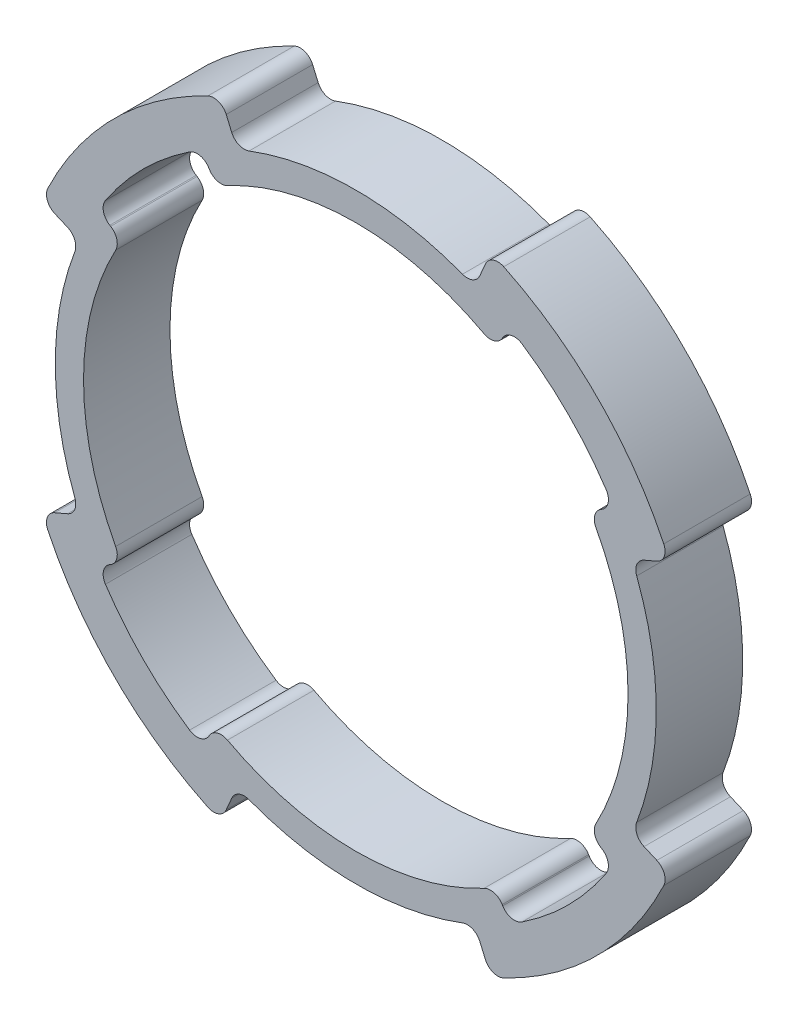
from build123d import *

# Parameters (mm, degrees)
SKETCH1_R                = 50.2
SKETCH1_R_2              = 40
BOSS_EXTRUDE1_DEPTH      = 12.7
CUT_EXTRUDE1_DEPTH       = 13.7
FILLET1_R                = 2
CIRPATTERN1_COUNT        = 4
FILLET1_OF_CIRPATTERN1_R = 2


with BuildPart() as part:
    # Sketch1 → Boss-Extrude1 (new body)
    with BuildSketch(Plane.XY):
        Circle(SKETCH1_R)
        Circle(SKETCH1_R_2, mode=Mode.SUBTRACT)
    extrude(amount=BOSS_EXTRUDE1_DEPTH)

    # Sketch2 → Cut-Extrude1 (cut, through all)
    with BuildSketch(Plane(origin=(0, 0, 0), x_dir=(-1, 0, 0), z_dir=(0, 0, -1))):
        with BuildLine():
            Line((-37.903382312, 22.639702058), (0, 0))
            Line((0, 0), (-22.639702058, 37.903382312))
            ThreePointArc((-22.639702058, 37.903382312), (-31.218764389, 31.218764389), (-37.903382312, 22.639702058))
        make_face()
        with BuildLine():
            Line((-46.112060645, 19.842325042), (-40.554730627, 17.450969136))
            ThreePointArc((-40.554730627, 17.450969136), (-44.15, 0), (-40.554730627, -17.450969136))
            Line((-40.554730627, -17.450969136), (-46.112060645, -19.842325042))
            ThreePointArc((-46.112060645, -19.842325042), (-50.2, 0), (-46.112060645, 19.842325042))
        make_face()
    cut_extrude1 = extrude(amount=-CUT_EXTRUDE1_DEPTH, mode=Mode.SUBTRACT)

    # Fillet1
    fillet1_edges = [part.edges().sort_by_distance(p)[0] for p in [
        (34.340550226, 20.511621344, 6.35),
        (20.511621344, 34.340550226, 6.35),
        (22.639702058, 37.903382312, 6.35),
        (37.903382312, 22.639702058, 6.35),
        (40.554730627, 17.450969136, 6.35),
        (40.554730627, -17.450969136, 6.35),
        (46.112060645, -19.842325042, 6.35),
        (46.112060645, 19.842325042, 6.35),
    ]]
    fillet(fillet1_edges, radius=FILLET1_R)

    # CirPattern1: Cut-Extrude1 ×4 about axis
    cirpattern1_axis = Axis((0, 0, 0), (0, 0, 1))
    for i in range(1, CIRPATTERN1_COUNT):
        add(cut_extrude1.rotate(cirpattern1_axis, i * 360 / CIRPATTERN1_COUNT), mode=Mode.SUBTRACT)

    # Fillet1 of CirPattern1
    fillet1_of_cirpattern1_edges = [part.edges().sort_by_distance(p)[0] for p in [
        (-20.511621344, 34.340550226, 6.35),
        (-34.340550226, 20.511621344, 6.35),
        (-37.903382312, 22.639702058, 6.35),
        (-22.639702058, 37.903382312, 6.35),
        (-17.450969136, 40.554730627, 6.35),
        (17.450969136, 40.554730627, 6.35),
        (19.842325042, 46.112060645, 6.35),
        (-19.842325042, 46.112060645, 6.35),
        (-34.340550226, -20.511621344, 6.35),
        (-20.511621344, -34.340550226, 6.35),
        (-22.639702058, -37.903382312, 6.35),
        (-37.903382312, -22.639702058, 6.35),
        (-40.554730627, -17.450969136, 6.35),
        (-40.554730627, 17.450969136, 6.35),
        (-46.112060645, 19.842325042, 6.35),
        (-46.112060645, -19.842325042, 6.35),
        (20.511621344, -34.340550226, 6.35),
        (34.340550226, -20.511621344, 6.35),
        (37.903382312, -22.639702058, 6.35),
        (22.639702058, -37.903382312, 6.35),
        (17.450969136, -40.554730627, 6.35),
        (-17.450969136, -40.554730627, 6.35),
        (-19.842325042, -46.112060645, 6.35),
        (19.842325042, -46.112060645, 6.35),
    ]]
    fillet(fillet1_of_cirpattern1_edges, radius=FILLET1_OF_CIRPATTERN1_R)


solid = part.part
